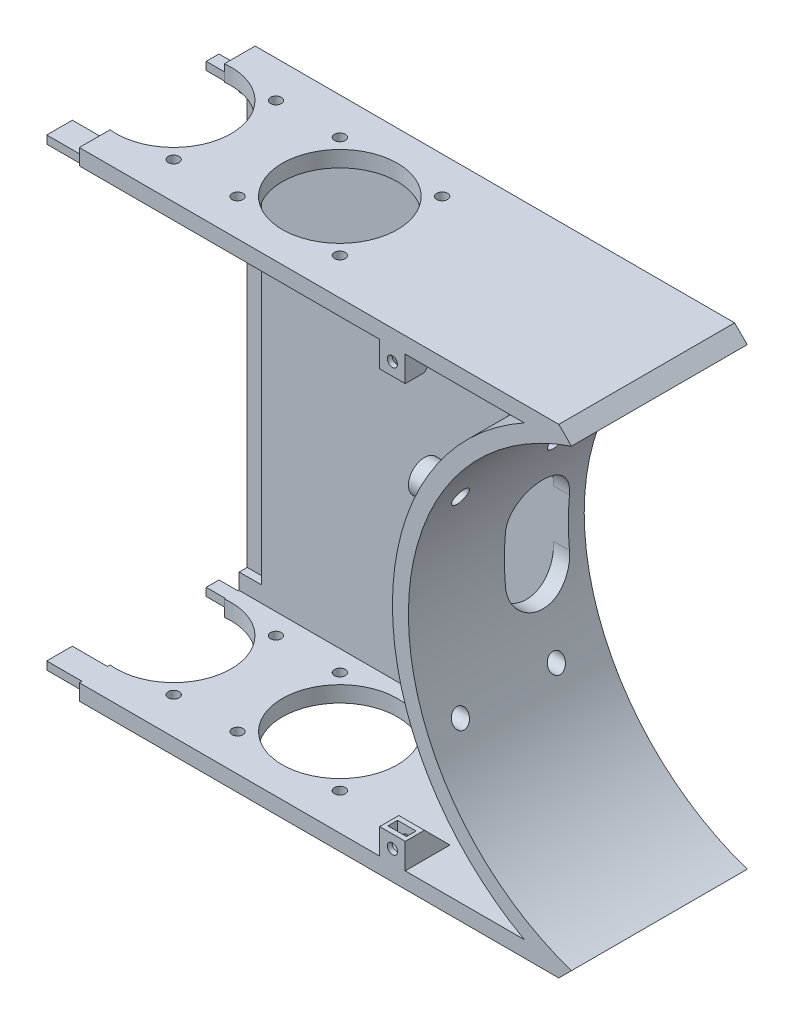
from build123d import *

# Parameters (mm, degrees)
SALIENTE_EXTRUIR1_DEPTH      = 55
CORTAR_EXTRUIR1_DEPTH        = 50
CORTAR_EXTRUIR2_DEPTH        = 82
CROQUIS4_R                   = 2.6
CORTAR_EXTRUIR3_DEPTH        = 82
SALIENTE_EXTRUIR2_REACH      = 266.813
SALIENTE_EXTRUIR2_END_RADIUS = 80
CROQUIS5_R                   = 5
CROQUIS5_R_2                 = 2.6
CROQUIS6_R                   = 1.6
CORTAR_EXTRUIR4_DEPTH        = 82
CROQUIS7_W                   = 11.2
CROQUIS7_H                   = 9.5
CORTAR_EXTRUIR5_DEPTH        = 13
CROQUIS8_W                   = 11.2
CROQUIS8_H                   = 12.4
CORTAR_EXTRUIR6_DEPTH        = 13
SALIENTE_EXTRUIR3_START      = 14.8
CROQUIS9_R                   = 4
CROQUIS9_R_2                 = 1.6
SALIENTE_EXTRUIR3_DEPTH      = 14.8
CROQUIS10_R                  = 1.7
CROQUIS10_R_2                = 18
CORTAR_EXTRUIR7_DEPTH        = 14.8
CORTAR_EXTRUIR8_DEPTH        = 1.5
CORTAR_EXTRUIR8_DEPTH_BACK   = 1.5
SALIENTE_EXTRUIR4_DEPTH      = 4
SALIENTE_EXTRUIR4_DEPTH_BACK = 4
SALIENTE_EXTRUIR5_DEPTH      = 4
CROQUIS13_R                  = 1.6
CORTAR_EXTRUIR9_DEPTH        = 14
CORTAR_EXTRUIR10_DEPTH       = 1.5
CORTAR_EXTRUIR10_DEPTH_BACK  = 1.5
CROQUIS18_W                  = 160
CROQUIS18_H                  = 200
CORTAR_EXTRUIR11_DEPTH       = 122
CROQUIS19_W                  = 22
CROQUIS19_H                  = 8
CROQUIS19_W_2                = 12
CROQUIS19_H_2                = 4
SALIENTE_EXTRUIR6_DEPTH      = 2.5
CROQUIS21_W                  = 14
CROQUIS21_H                  = 130
CORTAR_EXTRUIR12_DEPTH       = 2.5


with BuildPart() as part:
    # Croquis1 → Saliente-Extruir1 (new body)
    with BuildSketch(Plane.XY):
        with BuildLine():
            Line((-327.943684306, 75), (-327.943684306, -75))
            Line((-327.943684306, -75), (-27.943684306, -75))
            Line((-27.943684306, -75), (-24, -71.056315694))
            ThreePointArc((-24, -71.056315694), (-75, 0), (-24, 71.056315694))
            Line((-24, 71.056315694), (-27.943684306, 75))
            Line((-27.943684306, 75), (-327.943684306, 75))
        make_face()
    extrude(amount=SALIENTE_EXTRUIR1_DEPTH)

    # Croquis2 → Cortar-Extruir1 (cut)
    with BuildSketch(Plane.XY.offset(55)):
        with BuildLine():
            Line((-38.729833462, 70), (-322.943684306, 70))
            Line((-322.943684306, 70), (-322.943684306, -70))
            Line((-322.943684306, -70), (-38.729833462, -70))
            ThreePointArc((-38.729833462, -70), (-80, 0), (-38.729833462, 70))
        make_face()
    extrude(amount=-CORTAR_EXTRUIR1_DEPTH, mode=Mode.SUBTRACT)

    # Croquis3 → Cortar-Extruir2 (cut)
    with BuildSketch(Plane(origin=(0, 0, 0), x_dir=(0, 0, -1), z_dir=(1, 0, 0))):
        with BuildLine():
            Line((-5, 7.5), (-5, -7.5))
            ThreePointArc((-5, -7.5), (-15, -17.5), (-25, -7.5))
            Line((-25, -7.5), (-25, 7.5))
            ThreePointArc((-25, 7.5), (-15, 17.5), (-5, 7.5))
        make_face()
    extrude(amount=-CORTAR_EXTRUIR2_DEPTH, mode=Mode.SUBTRACT)

    # Croquis4 → Cortar-Extruir3 (cut)
    with BuildSketch(Plane(origin=(0, 0, 0), x_dir=(0, 0, -1), z_dir=(1, 0, 0))):
        with Locations((-45, -30)):
            Circle(CROQUIS4_R)
        with Locations((-15, -30)):
            Circle(CROQUIS4_R)
        with Locations((-15, 30)):
            Circle(CROQUIS4_R)
        with Locations((-45, 30)):
            Circle(CROQUIS4_R)
    extrude(amount=-CORTAR_EXTRUIR3_DEPTH, mode=Mode.SUBTRACT)

    # Saliente-Extruir2: up to this cylinder (the profile starts outside it)
    saliente_extruir2_end = Plane(origin=(0, 0, 25.141421), z_dir=(0, 0, 1)) * Cylinder(SALIENTE_EXTRUIR2_END_RADIUS, 724.626, mode=Mode.PRIVATE)
    # Croquis5 → Saliente-Extruir2 (add, up to the surface)
    with BuildSketch(Plane.ZY.offset(80), mode=Mode.PRIVATE) as saliente_extruir2_sk1:
        with Locations((45, 30)):
            Circle(CROQUIS5_R)
        with Locations((45, 30)):
            Circle(CROQUIS5_R_2, mode=Mode.SUBTRACT)
    saliente_extruir2_tool1 = extrude(saliente_extruir2_sk1.sketch, amount=-SALIENTE_EXTRUIR2_REACH, mode=Mode.PRIVATE) - saliente_extruir2_end
    add(saliente_extruir2_tool1.solids().sort_by_distance((-80, 30, 40.141421))[0])
    # Croquis5 → Saliente-Extruir2 (add, up to the surface)
    with BuildSketch(Plane.ZY.offset(80), mode=Mode.PRIVATE) as saliente_extruir2_sk2:
        with Locations((15, 30)):
            Circle(CROQUIS5_R)
        with Locations((15, 30)):
            Circle(CROQUIS5_R_2, mode=Mode.SUBTRACT)
    saliente_extruir2_tool2 = extrude(saliente_extruir2_sk2.sketch, amount=-SALIENTE_EXTRUIR2_REACH, mode=Mode.PRIVATE) - saliente_extruir2_end
    add(saliente_extruir2_tool2.solids().sort_by_distance((-80, 30, 10.141421))[0])
    # Croquis5 → Saliente-Extruir2 (add, up to the surface)
    with BuildSketch(Plane.ZY.offset(80), mode=Mode.PRIVATE) as saliente_extruir2_sk3:
        with Locations((45, -30)):
            Circle(CROQUIS5_R)
        with Locations((45, -30)):
            Circle(CROQUIS5_R_2, mode=Mode.SUBTRACT)
    saliente_extruir2_tool3 = extrude(saliente_extruir2_sk3.sketch, amount=-SALIENTE_EXTRUIR2_REACH, mode=Mode.PRIVATE) - saliente_extruir2_end
    add(saliente_extruir2_tool3.solids().sort_by_distance((-80, -30, 40.141421))[0])
    # Croquis5 → Saliente-Extruir2 (add, up to the surface)
    with BuildSketch(Plane.ZY.offset(80), mode=Mode.PRIVATE) as saliente_extruir2_sk4:
        with Locations((15, -30)):
            Circle(CROQUIS5_R)
        with Locations((15, -30)):
            Circle(CROQUIS5_R_2, mode=Mode.SUBTRACT)
    saliente_extruir2_tool4 = extrude(saliente_extruir2_sk4.sketch, amount=-SALIENTE_EXTRUIR2_REACH, mode=Mode.PRIVATE) - saliente_extruir2_end
    add(saliente_extruir2_tool4.solids().sort_by_distance((-80, -30, 10.141421))[0])

    # Croquis6 → Cortar-Extruir4 (cut)
    with BuildSketch(Plane.XY.offset(5)):
        with Locations((-302.943684306, 44)):
            Circle(CROQUIS6_R)
        with Locations((-317.943684306, -44)):
            Circle(CROQUIS6_R)
        with Locations((-190.943684306, 43)):
            Circle(CROQUIS6_R)
        with Locations((-102.943684306, 43)):
            Circle(CROQUIS6_R)
        with Locations((-102.943684306, -43)):
            Circle(CROQUIS6_R)
    extrude(amount=-CORTAR_EXTRUIR4_DEPTH, mode=Mode.SUBTRACT)

    # Croquis7 → Cortar-Extruir5 (cut)
    with BuildSketch(Plane.ZY.offset(327.943684306)):
        with Locations((26.9, 39.05)):
            Rectangle(CROQUIS7_W, CROQUIS7_H)
    extrude(amount=-CORTAR_EXTRUIR5_DEPTH, mode=Mode.SUBTRACT)

    # Croquis8 → Cortar-Extruir6 (cut)
    with BuildSketch(Plane.ZY.offset(327.943684306)):
        with Locations((14.1, -1.8)):
            Rectangle(CROQUIS8_W, CROQUIS8_H)
    extrude(amount=-CORTAR_EXTRUIR6_DEPTH, mode=Mode.SUBTRACT)

    # Croquis9 → Saliente-Extruir3 (add)
    # profile 1 of 5: a face of its own
    with BuildSketch(Plane.XY.offset(5).offset(SALIENTE_EXTRUIR3_START)):
        with Locations((-302.943684306, 44)):
            Circle(CROQUIS9_R)
        with Locations((-302.943684306, 44)):
            Circle(CROQUIS9_R_2, mode=Mode.SUBTRACT)
    # profile 2 of 5: a face of its own
    with BuildSketch(Plane.XY.offset(5).offset(SALIENTE_EXTRUIR3_START)):
        with Locations((-317.943684306, -44)):
            Circle(CROQUIS9_R)
        with Locations((-317.943684306, -44)):
            Circle(CROQUIS9_R_2, mode=Mode.SUBTRACT)
    # profile 3 of 5: a face of its own
    with BuildSketch(Plane.XY.offset(5).offset(SALIENTE_EXTRUIR3_START)):
        with Locations((-190.943684306, 43)):
            Circle(CROQUIS9_R)
        with Locations((-190.943684306, 43)):
            Circle(CROQUIS9_R_2, mode=Mode.SUBTRACT)
    # profile 4 of 5: a face of its own
    with BuildSketch(Plane.XY.offset(5).offset(SALIENTE_EXTRUIR3_START)):
        with Locations((-102.943684306, 43)):
            Circle(CROQUIS9_R)
        with Locations((-102.943684306, 43)):
            Circle(CROQUIS9_R_2, mode=Mode.SUBTRACT)
    # profile 5 of 5: a face of its own
    with BuildSketch(Plane.XY.offset(5).offset(SALIENTE_EXTRUIR3_START)):
        with Locations((-102.943684306, -43)):
            Circle(CROQUIS9_R)
        with Locations((-102.943684306, -43)):
            Circle(CROQUIS9_R_2, mode=Mode.SUBTRACT)
    extrude(amount=-SALIENTE_EXTRUIR3_DEPTH)

    # Croquis10 → Cortar-Extruir7 (cut)
    with BuildSketch(Plane.XZ.offset(75)):
        with Locations((-191.943684306, 43.5)):
            Circle(CROQUIS10_R)
        with Locations((-159.943684306, 43.5)):
            Circle(CROQUIS10_R)
        with Locations((-191.943684306, 11.5)):
            Circle(CROQUIS10_R)
        with Locations((-159.943684306, 11.5)):
            Circle(CROQUIS10_R)
        with Locations((-139.943684306, 43.5)):
            Circle(CROQUIS10_R)
        with Locations((-107.943684306, 43.5)):
            Circle(CROQUIS10_R)
        with Locations((-139.943684306, 11.5)):
            Circle(CROQUIS10_R)
        with Locations((-107.943684306, 11.5)):
            Circle(CROQUIS10_R)
        with Locations((-175.943684306, 27.5)):
            Circle(CROQUIS10_R_2)
        with Locations((-123.943684306, 27.5)):
            Circle(CROQUIS10_R_2)
    cortar_extruir7 = extrude(amount=-CORTAR_EXTRUIR7_DEPTH, mode=Mode.SUBTRACT)

    # Simetría1: Cortar-Extruir7 across plane
    add(cortar_extruir7.mirror(Plane.ZX), mode=Mode.SUBTRACT)

    # Croquis11 → Cortar-Extruir8 (cut, two sides: drawn at the far end of the back side and taken through both)
    with BuildSketch(Plane.XY.offset(13).offset(-CORTAR_EXTRUIR8_DEPTH_BACK)):
        Polygon((-301.268684306, 46.901185103), (-296.596208082, 46.901185103), (-296.596208082, 41.098814897), (-301.268684306, 41.098814897), (-304.618684306, 41.098814897), (-306.293684306, 44), (-304.618684306, 46.901185103), align=None)
        Polygon((-316.268684306, -41.098814897), (-319.618684306, -41.098814897), (-321.293684306, -44), (-319.618684306, -46.901185103), (-316.268684306, -46.901185103), (-310.721620957, -46.901185103), (-310.721620957, -41.098814897), align=None)
        Polygon((-187.593684306, 43), (-189.268684306, 45.901185103), (-192.618684306, 45.901185103), (-196.683445183, 45.901185103), (-196.683445183, 40.098814897), (-192.618684306, 40.098814897), (-189.268684306, 40.098814897), align=None)
        Polygon((-99.593684306, 43), (-101.268684306, 45.901185103), (-104.618684306, 45.901185103), (-110.770583293, 45.901185103), (-110.770583293, 40.098814897), (-104.618684306, 40.098814897), (-101.268684306, 40.098814897), align=None)
        Polygon((-99.593684306, -43), (-101.268684306, -40.098814897), (-104.618684306, -40.098814897), (-109.047231964, -40.098814897), (-109.167846689, -45.901185103), (-104.618684306, -45.901185103), (-101.268684306, -45.901185103), align=None)
    extrude(amount=CORTAR_EXTRUIR8_DEPTH + CORTAR_EXTRUIR8_DEPTH_BACK, mode=Mode.SUBTRACT)

    # Croquis12 → Saliente-Extruir4 (add, two sides: drawn at the far end of the back side and taken through both)
    with BuildSketch(Plane(origin=(0, 0, 0), x_dir=(1, 0, 0), z_dir=(0, 1, 0)).offset(-SALIENTE_EXTRUIR4_DEPTH_BACK)):
        Polygon((-322.943684306, -41), (-322.943684306, -55), (-314.943684306, -55), (-314.943684306, -49), align=None)
    extrude(amount=SALIENTE_EXTRUIR4_DEPTH + SALIENTE_EXTRUIR4_DEPTH_BACK)

    # Croquis14 → Saliente-Extruir5 (add, symmetric)
    with BuildSketch(Plane.ZY.offset(80)):
        Polygon((55, 70), (55, 62), (49, 62), (41, 70), align=None)
        Polygon((55, -70), (55, -62), (49, -62), (41, -70), align=None)
    saliente_extruir5 = extrude(amount=SALIENTE_EXTRUIR5_DEPTH, both=True)

    # Croquis13 → Cortar-Extruir9 (cut)
    with BuildSketch(Plane.XY.offset(55)):
        with Locations((-318.943684306, 0)):
            Circle(CROQUIS13_R)
        with Locations((-80, -66)):
            Circle(CROQUIS13_R)
        with Locations((-80, 66)):
            Circle(CROQUIS13_R)
    cortar_extruir9 = extrude(amount=-CORTAR_EXTRUIR9_DEPTH, mode=Mode.SUBTRACT)

    # Simetría2: Saliente-Extruir5, Cortar-Extruir9 across plane
    add(saliente_extruir5.mirror(Plane.ZY.offset(160)))
    add(cortar_extruir9.mirror(Plane.ZY.offset(160)), mode=Mode.SUBTRACT)

    # Croquis17 → Cortar-Extruir10 (cut, two sides: drawn at the far end of the back side and taken through both)
    with BuildSketch(Plane.XY.offset(52).offset(-CORTAR_EXTRUIR10_DEPTH_BACK)):
        Polygon((-317.268684306, 2.901185103), (-320.618684306, 2.901185103), (-322.293684306, 0), (-320.618684306, -2.901185103), (-317.268684306, -2.901185103), (-310.618684306, -2.901185103), (-310.618684306, 2.901185103), align=None)
        Polygon((-242.901185103, -64.325), (-242.901185103, -67.675), (-240, -69.35), (-237.098814897, -67.675), (-237.098814897, -64.325), (-237.098814897, -57.675), (-242.901185103, -57.675), align=None)
        Polygon((-82.901185103, -64.325), (-82.901185103, -67.675), (-80, -69.35), (-77.098814897, -67.675), (-77.098814897, -64.325), (-77.098814897, -57.675), (-82.901185103, -57.675), align=None)
        Polygon((-77.098814897, 64.325), (-77.098814897, 67.675), (-80, 69.35), (-82.901185103, 67.675), (-82.901185103, 64.325), (-82.901185103, 57.675), (-76.887318252, 57.675), align=None)
        Polygon((-237.098814897, 64.325), (-237.098814897, 67.675), (-240, 69.35), (-242.901185103, 67.675), (-242.901185103, 64.325), (-242.901185103, 57.675), (-237.098814897, 57.675), align=None)
    extrude(amount=CORTAR_EXTRUIR10_DEPTH + CORTAR_EXTRUIR10_DEPTH_BACK, mode=Mode.SUBTRACT)

    # Croquis18 → Cortar-Extruir11 (cut)
    with BuildSketch(Plane.XY):
        with Locations((-257.943684306, 0)):
            Rectangle(CROQUIS18_W, CROQUIS18_H)
    extrude(amount=CORTAR_EXTRUIR11_DEPTH, mode=Mode.SUBTRACT)

    # Croquis19 → Saliente-Extruir6 (add)
    with BuildSketch(Plane(origin=(0, -70, 0), x_dir=(1, 0, 0), z_dir=(0, 1, 0))):
        with Locations((-177.943684306, -50.19427191)):
            Rectangle(CROQUIS19_W, CROQUIS19_H)
        with Locations((-177.943684306, -7.30572809)):
            Rectangle(CROQUIS19_W_2, CROQUIS19_H_2)
    saliente_extruir6 = extrude(amount=-SALIENTE_EXTRUIR6_DEPTH)

    # Simetría3: Saliente-Extruir6 across plane
    add(saliente_extruir6.mirror(Plane.ZX))

    # Croquis21 → Cortar-Extruir12 (cut)
    with BuildSketch(Plane.XY.offset(5)):
        with Locations((-177.943684306, 0)):
            Rectangle(CROQUIS21_W, CROQUIS21_H)
    extrude(amount=-CORTAR_EXTRUIR12_DEPTH, mode=Mode.SUBTRACT)


solid = part.part
